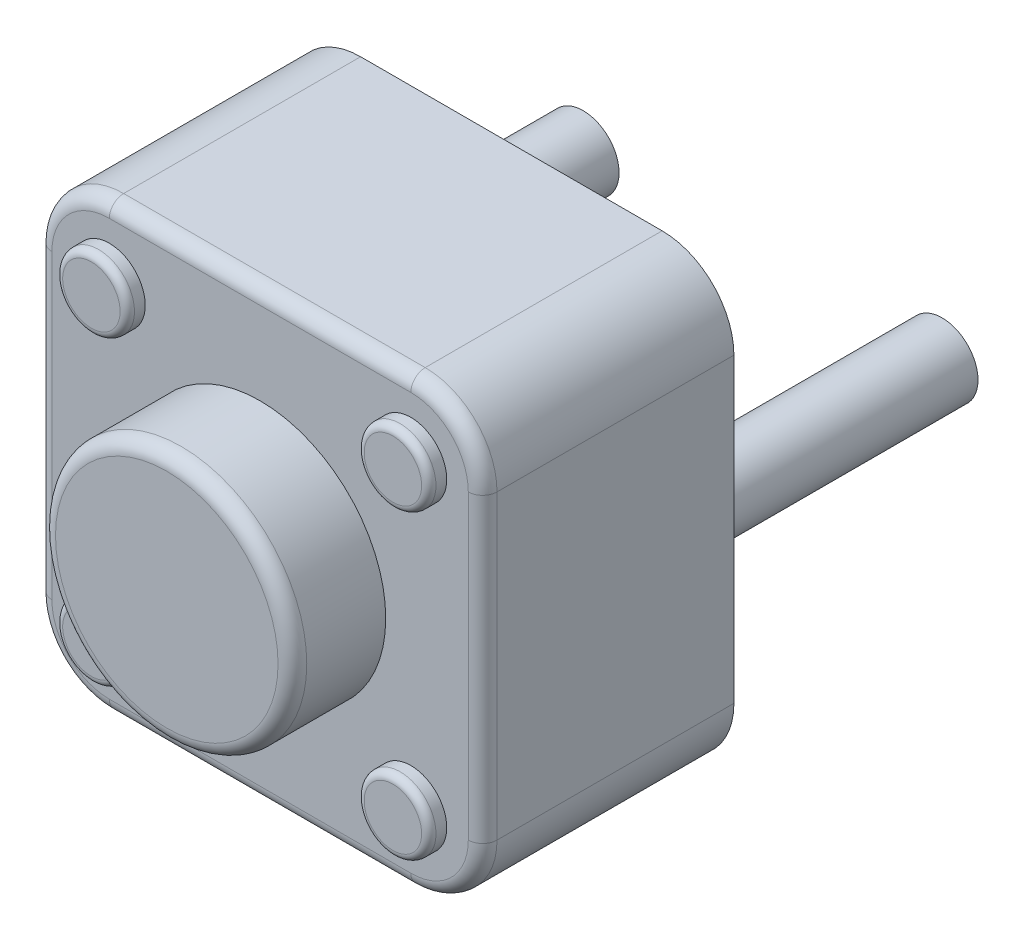
from build123d import *

# Parameters (mm, degrees)
SKETCH1_W           = 6.2
SKETCH1_H           = 6.2
BOSS_EXTRUDE1_DEPTH = 3.5
SKETCH2_W           = 0.5
SKETCH2_H           = 3.5
SKETCH3_W           = 0.5
SKETCH3_H           = 3.5
SKETCH4_W           = 0.5
SKETCH4_H           = 0.25
SKETCH5_W           = 0.5
SKETCH5_H           = 0.25
SKETCH6_W           = 0.5
SKETCH6_H           = 0.25
SKETCH7_W           = 1.75
SKETCH7_H           = 1.3
SKETCH8_W           = 0.5
SKETCH8_H           = 0.25
FILLET1_R           = 1
FILLET2_R           = 0.1
FILLET3_R           = 0.2


with BuildPart() as part:
    # Sketch1 → Boss-Extrude1 (new body)
    with BuildSketch(Plane.XY.offset(3.5)):
        Rectangle(SKETCH1_W, SKETCH1_H)
    extrude(amount=-BOSS_EXTRUDE1_DEPTH)

    # Sketch2 → Revolve1 (revolve)
    with BuildSketch(Plane(origin=(0, 0, 0), x_dir=(1, 0, 0), z_dir=(0, 1, 0))):
        with Locations((2.75, 1.75)):
            Rectangle(SKETCH2_W, SKETCH2_H)
    revolve(axis=Axis((2.5, 0, -3.5), (0, 0, 1)))

    # Sketch3 → Revolve2 (revolve)
    with BuildSketch(Plane(origin=(0, 0, 0), x_dir=(1, 0, 0), z_dir=(0, 1, 0))):
        with Locations((-2.25, 1.75)):
            Rectangle(SKETCH3_W, SKETCH3_H)
    revolve(axis=Axis((-2.5, 0, -3.5), (0, 0, 1)))

    # Sketch4 → Revolve3 (revolve)
    with BuildSketch(Plane.XZ.offset(2.1)):
        with Locations((2.35, 3.625)):
            Rectangle(SKETCH4_W, SKETCH4_H)
    revolve(axis=Axis((2.1, -2.1, 3.75), (0, 0, -1)))

    # Sketch5 → Revolve4 (revolve)
    with BuildSketch(Plane.XZ.offset(-2.1)):
        with Locations((2.35, 3.625)):
            Rectangle(SKETCH5_W, SKETCH5_H)
    revolve(axis=Axis((2.1, 2.1, 3.75), (0, 0, -1)))

    # Sketch6 → Revolve5 (revolve)
    with BuildSketch(Plane.XZ.offset(-2.1)):
        with Locations((-1.85, 3.625)):
            Rectangle(SKETCH6_W, SKETCH6_H)
    revolve(axis=Axis((-2.1, 2.1, 3.75), (0, 0, -1)))

    # Sketch7 → Revolve6 (revolve)
    with BuildSketch(Plane.XZ):
        with Locations((0.875, 4.15)):
            Rectangle(SKETCH7_W, SKETCH7_H)
    revolve(axis=Axis((0, 0, 4.8), (0, 0, -1)))

    # Sketch8 → Revolve7 (revolve)
    with BuildSketch(Plane.XZ.offset(2.1)):
        with Locations((-1.85, 3.625)):
            Rectangle(SKETCH8_W, SKETCH8_H)
    revolve(axis=Axis((-2.1, -2.1, 3.75), (0, 0, -1)))

    # Fillet1
    fillet1_edges = [part.edges().sort_by_distance(p)[0] for p in [
        (3.1, -3.1, 1.75),
        (-3.1, -3.1, 1.75),
        (-3.1, 3.1, 1.75),
        (3.1, 3.1, 1.75),
    ]]
    fillet(fillet1_edges, radius=FILLET1_R)

    # Fillet2
    fillet2_edges = [part.edges().sort_by_distance(p)[0] for p in [
        (1.6, -2.1, 3.75),
        (1.6, 2.1, 3.75),
        (-2.6, 2.1, 3.75),
        (-2.6, -2.1, 3.75),
    ]]
    fillet(fillet2_edges, radius=FILLET2_R)

    # Fillet3
    fillet3_edges = [part.edges().sort_by_distance(p)[0] for p in [
        (-1.75, 0, 4.8),
        (0, -3.1, 3.5),
        (3.1, 0, 3.5),
        (0, 3.1, 3.5),
        (-3.1, 0, 3.5),
        (-2.807106781, -2.807106781, 3.5),
        (-2.807106781, 2.807106781, 3.5),
        (2.807106781, 2.807106781, 3.5),
        (2.807106781, -2.807106781, 3.5),
    ]]
    fillet(fillet3_edges, radius=FILLET3_R)


solid = part.part
